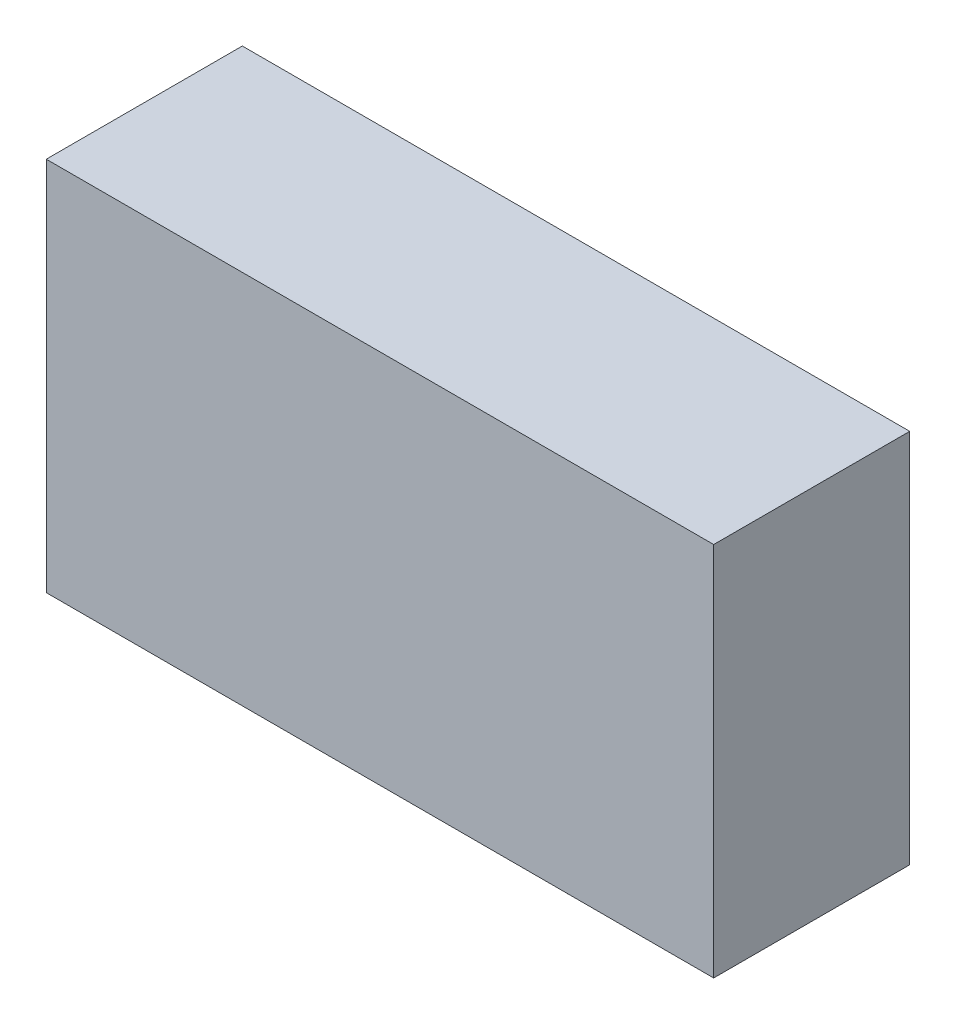
from build123d import *

# Parameters (mm, degrees)
SKETCH_1_W      = 8
SKETCH_1_H      = 4.5
EXTRUDE_1_DEPTH = 2.35


with BuildPart() as part:
    # 草图1 → 凸台-拉伸1 (new body)
    with BuildSketch(Plane.XY):
        with Locations((4, 2.25)):
            Rectangle(SKETCH_1_W, SKETCH_1_H)
    extrude(amount=EXTRUDE_1_DEPTH)


solid = part.part
